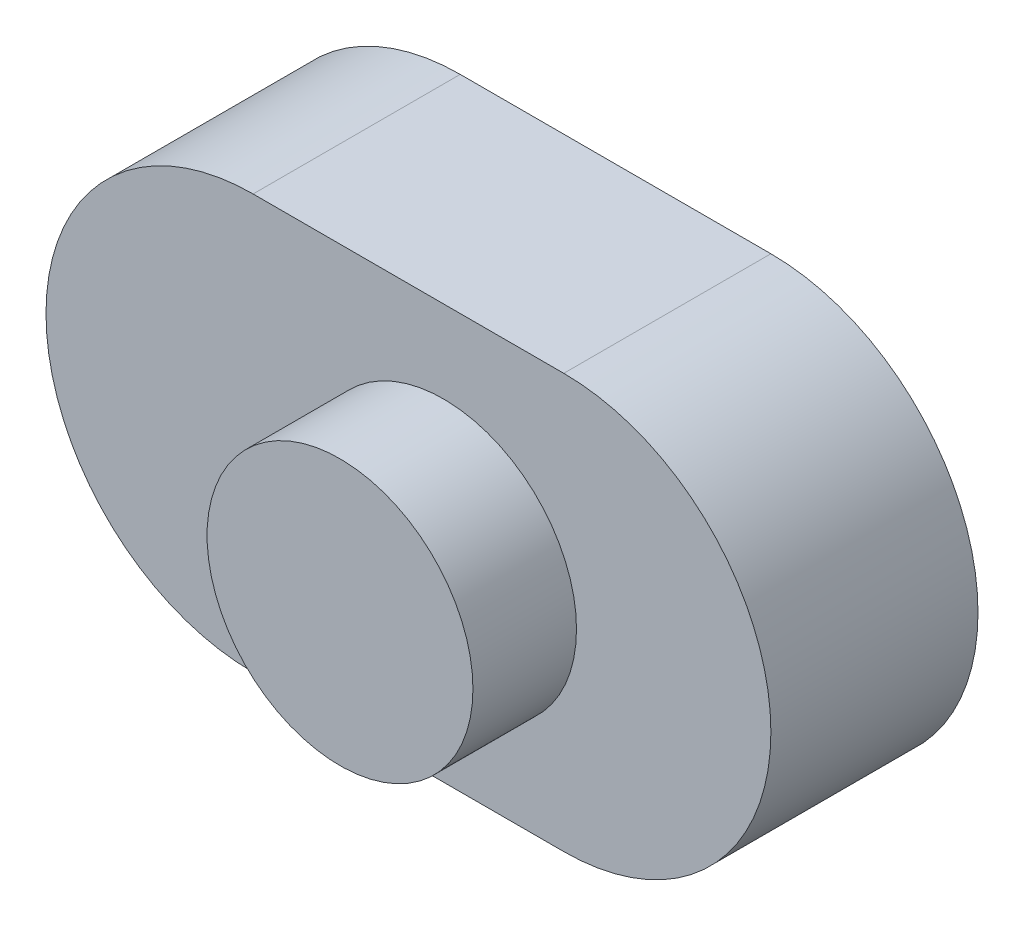
from build123d import *

# Parameters (mm, degrees)
SALIENTE_EXTRUIR1_DEPTH = 10
CROQUIS2_R              = 6.418605164
SALIENTE_EXTRUIR2_DEPTH = 5


with BuildPart() as part:
    # Croquis1 → Saliente-Extruir1 (new body)
    with BuildSketch(Plane.XY):
        with BuildLine():
            Line((-55.369792261, 7.493056697), (-40.369792261, 7.493056697))
            ThreePointArc((-40.369792261, 7.493056697), (-30.369792261, -2.506943303), (-40.369792261, -12.506943303))
            Line((-40.369792261, -12.506943303), (-55.369792261, -12.506943303))
            ThreePointArc((-55.369792261, -12.506943303), (-65.369792261, -2.506943303), (-55.369792261, 7.493056697))
        make_face()
    extrude(amount=SALIENTE_EXTRUIR1_DEPTH)

    # Croquis2 → Saliente-Extruir2 (add)
    with BuildSketch(Plane.XY.offset(10)):
        with Locations((-46.174536974, -2.897909692)):
            Circle(CROQUIS2_R)
    extrude(amount=SALIENTE_EXTRUIR2_DEPTH)


solid = part.part
